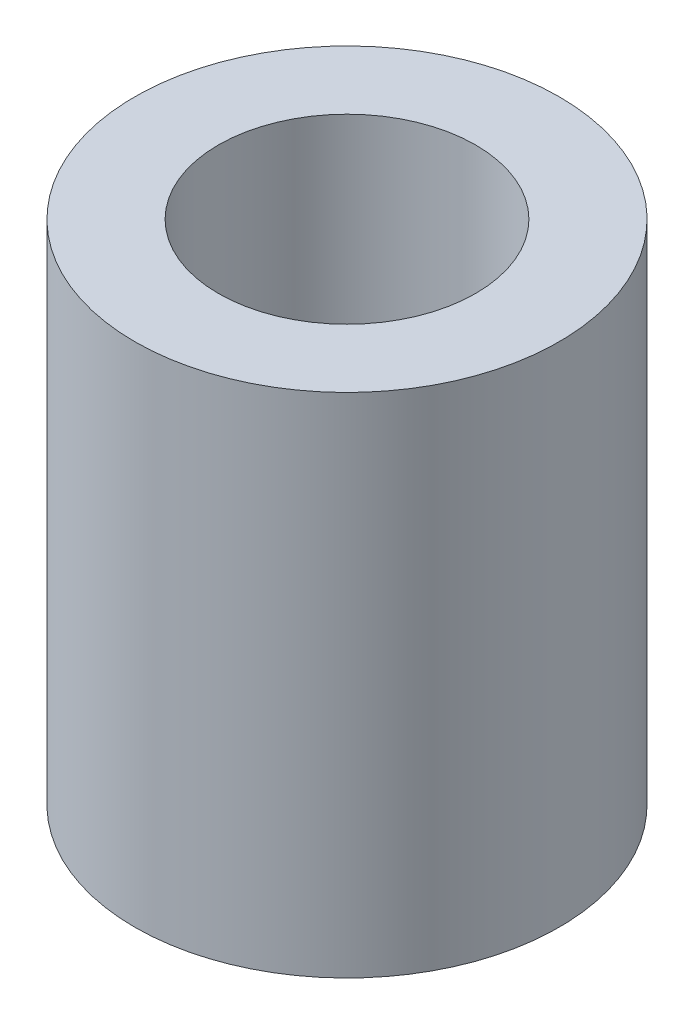
from build123d import *

# Parameters (mm, degrees)
SKETCH1_R           = 3.975
BOSS_EXTRUDE1_DEPTH = 9.5
SKETCH2_R           = 2.41
CUT_EXTRUDE1_DEPTH  = 10.5


with BuildPart() as part:
    # Sketch1 → Boss-Extrude1 (new body)
    with BuildSketch(Plane(origin=(0, 0, 0), x_dir=(1, 0, 0), z_dir=(0, 1, 0))):
        Circle(SKETCH1_R)
    extrude(amount=BOSS_EXTRUDE1_DEPTH)

    # Sketch2 → Cut-Extrude1 (cut, through all)
    with BuildSketch(Plane(origin=(0, 9.5, 0), x_dir=(1, 0, 0), z_dir=(0, 1, 0))):
        Circle(SKETCH2_R)
    extrude(amount=-CUT_EXTRUDE1_DEPTH, mode=Mode.SUBTRACT)


solid = part.part
